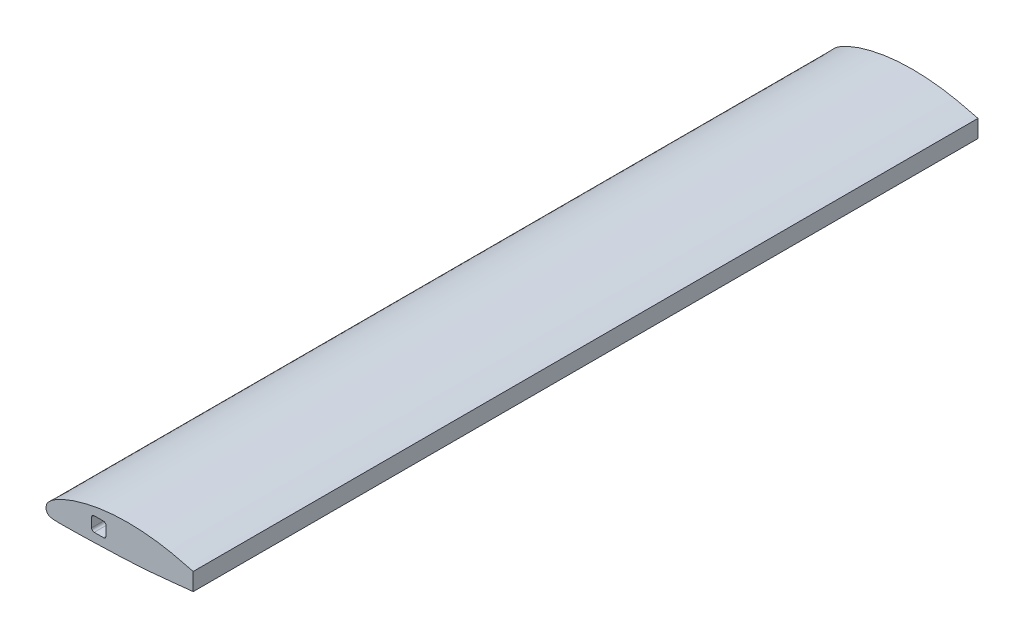
from build123d import *

# Parameters (mm, degrees)
BOSS_EXTRUDE2_DEPTH = 1557.3248


with BuildPart() as part:
    # Sketch4 → Boss-Extrude2 (new body)
    with BuildSketch(Plane.XY):
        with BuildLine():
            Line((292.1, 1.333976234), (292.1, 36.089138265))
            add(Edge.make_bspline(
                [(292.1, 36.089138265), (291.712067661, 36.184325378), (287.400368227, 37.248919845), (279.147802785, 39.48983049), (267.187027603, 42.40924598), (255.03469047, 45.168428419), (242.72118539, 47.650209376), (230.296228944, 49.833894591), (217.801864375, 51.680006577), (205.284000487, 53.175668631), (192.786307767, 54.307105516), (180.352488326, 55.055153751), (168.027001927, 55.419018534), (155.853682434, 55.415704887), (143.87484882, 55.043188606), (132.132886758, 54.31287262), (120.66707402, 53.241130474), (109.522615964, 51.802214496), (98.737214119, 50.046324189), (88.347101396, 48.018984454), (78.388903375, 45.752295043), (68.897602741, 43.276072625), (59.906772527, 40.616983942), (51.447808112, 37.802843474), (43.549919517, 34.862025865), (36.241276719, 31.820931595), (29.547220551, 28.707908655), (23.489975501, 25.553233337), (18.091178224, 22.384144218), (13.365884381, 19.2305327), (9.330250208, 16.113817985), (5.969851951, 13.038999763), (3.345197754, 9.938584311), (1.180192797, 6.535708142), (0.479614476, 3.079908406), (-0.173094538, -0.266173519), (0.240253697, -3.332942929), (1.378230663, -6.423813499), (3.229176053, -9.150211891), (5.896039459, -11.320678389), (9.37076014, -12.591423064), (13.453435799, -13.208305962), (18.177942301, -13.543713588), (23.569117067, -13.71233198), (29.61826198, -13.823243233), (36.304218059, -13.633510343), (43.607365535, -13.749516921), (51.499077676, -13.570479283), (59.953218347, -13.425446573), (68.939511532, -13.223717363), (78.426543, -12.998167708), (88.380880035, -12.741679467), (98.76735409, -12.457031064), (109.549481724, -12.140459653), (120.689292625, -11.788758271), (132.147836589, -11.396110922), (143.884459541, -10.953513815), (155.858263106, -10.452803048), (168.02720614, -9.869990689), (180.347887973, -9.165777547), (192.776520036, -8.328984733), (205.269979931, -7.367125203), (217.783705172, -6.283597235), (230.273405672, -5.088105923), (242.69443158, -3.805728614), (255.003698462, -2.484737799), (267.159514579, -1.183928962), (279.11891019, 0.06085411), (287.411482757, 0.884854057), (291.712223024, 1.296948262), (292.1, 1.333976234)],
                knots=[0.151635715, 0.151635715, 0.151635715, 0.151635715, 0.15301104, 0.166927615, 0.181082, 0.19540448, 0.209838051, 0.224332605, 0.238841949, 0.253325073, 0.267739982, 0.282048685, 0.296212777, 0.310196043, 0.323962314, 0.337476235, 0.350702495, 0.363610632, 0.376163959, 0.388325705, 0.400058826, 0.41132739, 0.422098222, 0.43233946, 0.442020271, 0.451113163, 0.459592207, 0.467434959, 0.474622154, 0.48114013, 0.486983094, 0.492171114, 0.496782496, 0.500970226, 0.505871632, 0.508789423, 0.512670174, 0.516325668, 0.520069902, 0.523879651, 0.527960743, 0.532641784, 0.538069255, 0.544264221, 0.551214848, 0.558899645, 0.567291448, 0.576362099, 0.586079537, 0.596409112, 0.607314709, 0.618758332, 0.630699138, 0.643094929, 0.655903573, 0.669079202, 0.6825766, 0.696348373, 0.710348009, 0.724529116, 0.738844327, 0.753243365, 0.767678182, 0.782097111, 0.79644888, 0.810678263, 0.824728613, 0.838547559, 0.852083943, 0.85342536, 0.85342536, 0.85342536, 0.85342536], degree=3))
        make_face()
        with BuildLine():
            Line((95.631, 33.590938522), (113.919, 33.590938522))
            ThreePointArc((113.919, 33.590938522), (117.511102448, 32.10304097), (118.999, 28.510938522))
            Line((118.999, 28.510938522), (118.999, 10.222938522))
            ThreePointArc((118.999, 10.222938522), (117.511102448, 6.630836073), (113.919, 5.142938522))
            Line((113.919, 5.142938522), (95.631, 5.142938522))
            ThreePointArc((95.631, 5.142938522), (92.038897552, 6.630836073), (90.551, 10.222938522))
            Line((90.551, 10.222938522), (90.551, 28.510938522))
            ThreePointArc((90.551, 28.510938522), (92.038897552, 32.10304097), (95.631, 33.590938522))
        make_face(mode=Mode.SUBTRACT)
    extrude(amount=BOSS_EXTRUDE2_DEPTH)


solid = part.part
